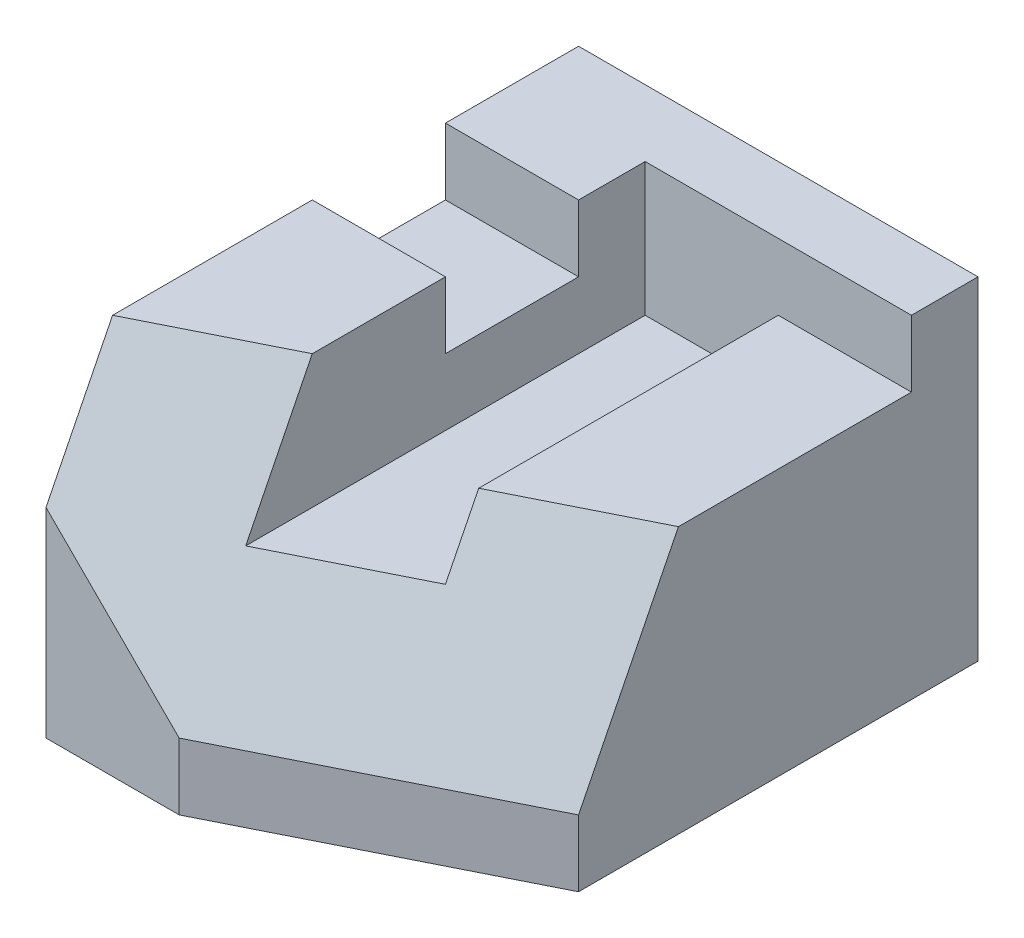
from build123d import *

# Parameters (mm, degrees)
SKETCH1_W           = 60
SKETCH1_H           = 80
BOSS_EXTRUDE1_DEPTH = 50
CUT_EXTRUDE1_DEPTH  = 70
SKETCH7_W           = 20
SKETCH7_H           = 10
CUT_EXTRUDE6_DEPTH  = 70
CUT_EXTRUDE7_DEPTH  = 70
CUT_EXTRUDE8_DEPTH  = 70


with BuildPart() as part:
    # Sketch1 → Boss-Extrude1 (new body)
    with BuildSketch(Plane(origin=(0, 0, 0), x_dir=(1, 0, 0), z_dir=(0, 1, 0))):
        Rectangle(SKETCH1_W, SKETCH1_H)
    extrude(amount=BOSS_EXTRUDE1_DEPTH)

    # Sketch2 → Cut-Extrude1 (cut)
    with BuildSketch(Plane.XY.offset(40)):
        Polygon((30, 40), (10, 40), (10, 30), (-10, 30), (-10, 50), (30, 50), align=None)
    extrude(amount=-CUT_EXTRUDE1_DEPTH, mode=Mode.SUBTRACT)

    # Sketch7 → Cut-Extrude6 (cut)
    with BuildSketch(Plane.ZY.offset(30)):
        with Locations((-10, 45)):
            Rectangle(SKETCH7_W, SKETCH7_H)
    extrude(amount=-CUT_EXTRUDE6_DEPTH, mode=Mode.SUBTRACT)

    # Sketch8 → Cut-Extrude7 (cut)
    with BuildSketch(Plane.XZ):
        Polygon((30, 40), (30, 20), (-10, 40), align=None)
    extrude(amount=-CUT_EXTRUDE7_DEPTH, mode=Mode.SUBTRACT)

    # 3DSketch6 → Cut-Extrude8 (cut, along a direction that is not the sketch's normal)
    with BuildSketch(Plane(origin=(-30, 50, 30), x_dir=(0.8241633836921342, -0.5494422557947563, -0.13736056394868917), z_dir=(0.408248290463863, 0.40824829046386274, 0.8164965809277263))):
        Polygon((0, 0), (17.856873313, 13.458531698), (27.47211279, -6.729265849), (45.328986103, 6.729265849), (40.521366365, 16.823164623), (58.378239678, 30.281696321), (72.801098893, 0), (37.087352266, -26.917063396), (9.615239476, -20.187797547), align=None)
    extrude(amount=CUT_EXTRUDE8_DEPTH, dir=(0, 0, 1), mode=Mode.SUBTRACT)


solid = part.part
